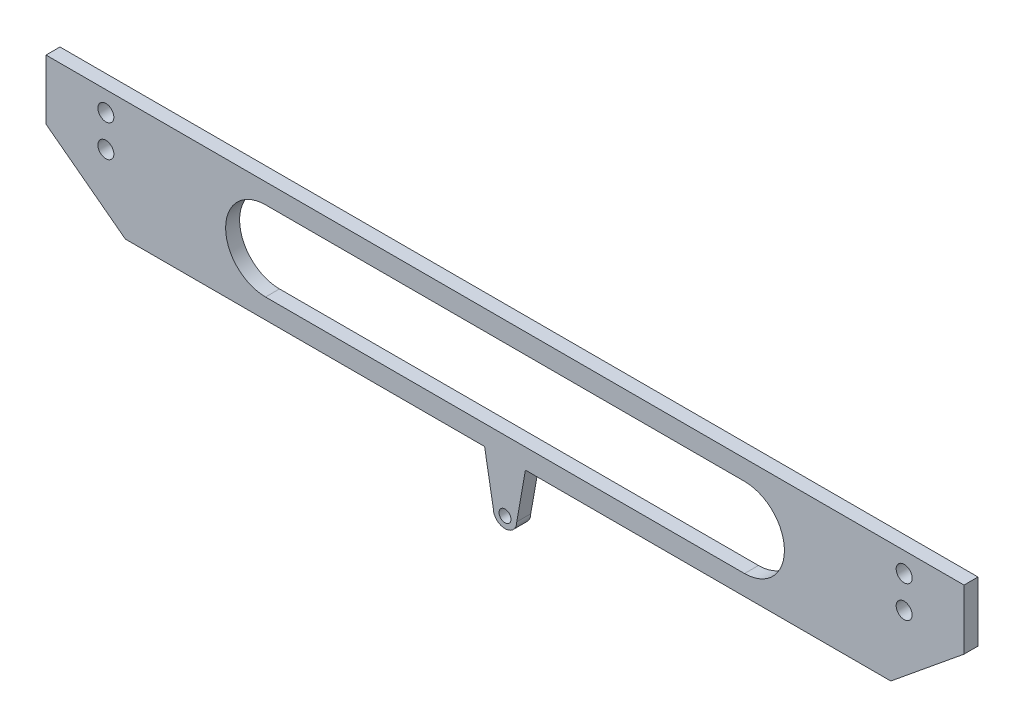
from build123d import *

# Parameters (mm, degrees)
SKETCH4_R           = 1.5
BOSS_EXTRUDE1_DEPTH = 3.5
SKETCH6_R           = 2
CUT_EXTRUDE1_DEPTH  = 10


with BuildPart() as part:
    # Sketch4 → Boss-Extrude1 (new body)
    with BuildSketch(Plane.XY):
        with BuildLine():
            Line((59.884076231, 77.5), (62.057311876, 65.174968198))
            ThreePointArc((62.057311876, 65.174968198), (65, 62.232280074), (67.942688124, 65.174968198))
            Line((67.942688124, 65.174968198), (70.115923769, 77.5))
            Line((70.115923769, 77.5), (161.654067638, 77.5))
            Line((161.654067638, 77.5), (180, 92.5))
            Line((180, 92.5), (180, 107.5))
            Line((180, 107.5), (-50, 107.5))
            Line((-50, 107.5), (-50, 92.5))
            Line((-50, 92.5), (-30.115923769, 77.5))
            Line((-30.115923769, 77.5), (59.884076231, 77.5))
        make_face()
        with Locations((65, 65)):
            Circle(SKETCH4_R, mode=Mode.SUBTRACT)
        with BuildLine():
            Line((125, 82.5), (5, 82.5))
            ThreePointArc((5, 82.5), (-5, 92.5), (5, 102.5))
            Line((5, 102.5), (125, 102.5))
            ThreePointArc((125, 102.5), (135, 92.5), (125, 82.5))
        make_face(mode=Mode.SUBTRACT)
    extrude(amount=-BOSS_EXTRUDE1_DEPTH)

    # Sketch6 → Cut-Extrude1 (cut)
    with BuildSketch(Plane.XY):
        with Locations((-35, 102.5)):
            Circle(SKETCH6_R)
        with Locations((-35, 94.5)):
            Circle(SKETCH6_R)
        with Locations((165, 94.5)):
            Circle(SKETCH6_R)
        with Locations((165, 102.5)):
            Circle(SKETCH6_R)
    extrude(amount=-CUT_EXTRUDE1_DEPTH, mode=Mode.SUBTRACT)


solid = part.part
